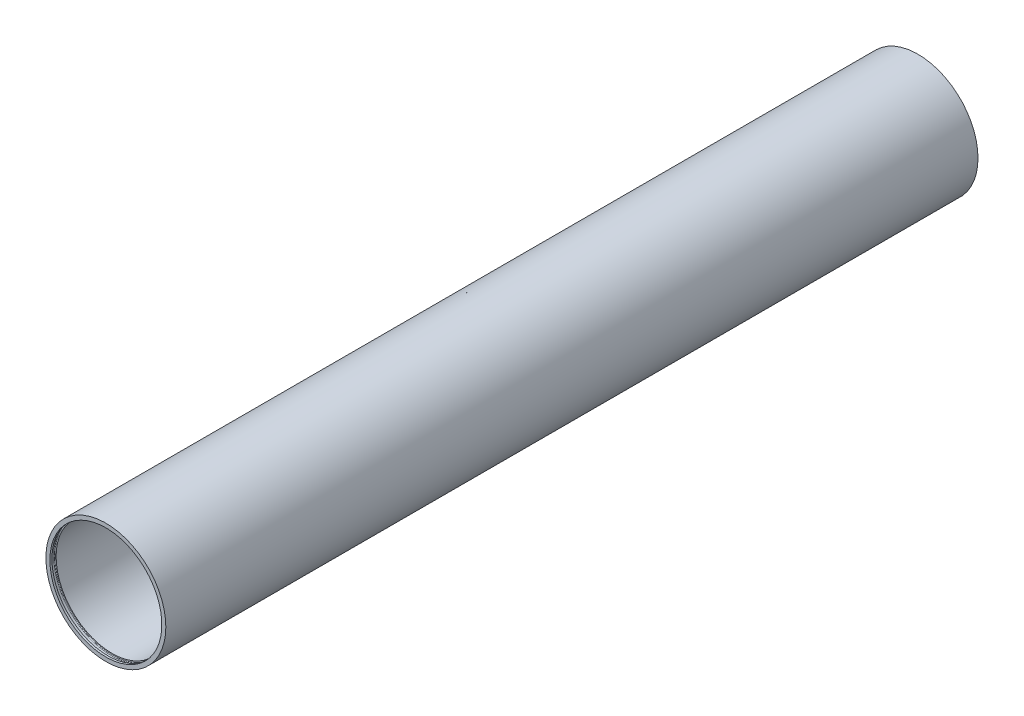
from build123d import *

# Parameters (mm, degrees)
SKETCH1_R           = 37.500000057
BOSS_EXTRUDE1_DEPTH = 507.84
SKETCH3_R           = 35
CUT_EXTRUDE1_DEPTH  = 507.84


with BuildPart() as part:
    # Sketch1 → Boss-Extrude1 (new body)
    with BuildSketch(Plane.XY):
        Circle(SKETCH1_R)
    extrude(amount=BOSS_EXTRUDE1_DEPTH)

    # Sketch3 → Cut-Extrude1 (cut)
    with BuildSketch(Plane(origin=(0, 0, 0), x_dir=(-1, 0, 0), z_dir=(0, 0, -1))):
        Circle(SKETCH3_R)
    extrude(amount=-CUT_EXTRUDE1_DEPTH, mode=Mode.SUBTRACT)

    # Sketch9 → Groove for ANSI B27.7 - 3BM1-68_ Basic I (revolve, cut)
    with BuildSketch(Plane(origin=(0, 0, 507.84), x_dir=(0, 1, 0), z_dir=(-1, 0, 0))):
        with BuildLine():
            Line((35.7, 503.96), (31.5, 503.96))
            Line((31.5, 503.96), (31.5, 506.57))
            Line((31.5, 506.57), (35.7, 506.57))
            ThreePointArc((35.7, 506.57), (35.982842712, 506.452842712), (36.1, 506.17))
            Line((36.1, 506.17), (36.1, 504.36))
            ThreePointArc((36.1, 504.36), (35.982842712, 504.077157288), (35.7, 503.96))
        make_face()
    revolve(axis=Axis((0, 0, 557.84), (0, 0, -1)), mode=Mode.SUBTRACT)

    # Sketch11 → Groove for ANSI B27.7 - 3BM1-68_ Bas 2 (revolve, cut)
    with BuildSketch(Plane(origin=(0, 0, 507.84), x_dir=(0, 1, 0), z_dir=(-1, 0, 0))):
        with BuildLine():
            Line((35.7, 1.27), (31.5, 1.27))
            Line((31.5, 1.27), (31.5, 3.88))
            Line((31.5, 3.88), (35.7, 3.88))
            ThreePointArc((35.7, 3.88), (35.982842712, 3.762842712), (36.1, 3.48))
            Line((36.1, 3.48), (36.1, 1.67))
            ThreePointArc((36.1, 1.67), (35.982842712, 1.387157288), (35.7, 1.27))
        make_face()
    revolve(axis=Axis((0, 0, 557.84), (0, 0, -1)), mode=Mode.SUBTRACT)


solid = part.part
